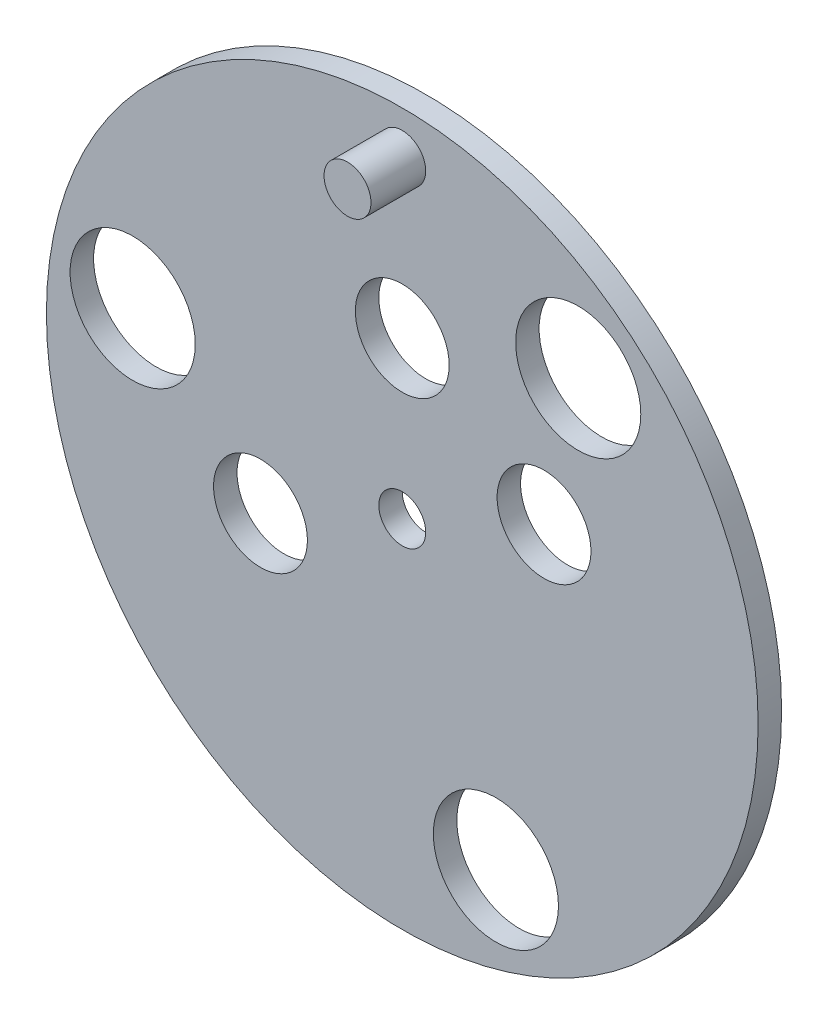
from build123d import *

# Parameters (mm, degrees)
SKETCH1_R           = 227.5
BOSS_EXTRUDE1_DEPTH = 7.5
BOSS_EXTRUDE2_START = 7.5
SKETCH1_3_R         = 15
BOSS_EXTRUDE2_DEPTH = 35
SKETCH2_R           = 40
SKETCH2_R_2         = 30
CUT_EXTRUDE1_DEPTH  = 16
CUT_EXTRUDE3_START  = 7.5
SKETCH3_R           = 15
CUT_EXTRUDE3_DEPTH  = 15


with BuildPart() as part:
    # Sketch1 → Boss-Extrude1 (new body, symmetric)
    with BuildSketch(Plane.XY):
        Circle(SKETCH1_R)
    extrude(amount=BOSS_EXTRUDE1_DEPTH, both=True)

    # Sketch1_3 → Boss-Extrude2 (add)
    with BuildSketch(Plane.XY.offset(BOSS_EXTRUDE2_START)):
        with Locations((0, 200)):
            Circle(SKETCH1_3_R)
    extrude(amount=BOSS_EXTRUDE2_DEPTH)

    # Sketch2 → Cut-Extrude1 (cut, through all)
    with BuildSketch(Plane.XY.offset(7.5)):
        with Locations((-172.341356777, 30.388431092)):
            Circle(SKETCH2_R)
        with Locations((0, 100)):
            Circle(SKETCH2_R_2)
        with Locations((90.630778704, 42.261826174)):
            Circle(SKETCH2_R_2)
        with Locations((-90.630778704, -42.261826174)):
            Circle(SKETCH2_R_2)
        with Locations((112.487831695, 134.057777546)):
            Circle(SKETCH2_R)
        with Locations((59.853525082, -164.446208638)):
            Circle(SKETCH2_R)
    extrude(amount=-CUT_EXTRUDE1_DEPTH, mode=Mode.SUBTRACT)

    # Sketch3 → Cut-Extrude3 (cut)
    with BuildSketch(Plane.XY.offset(CUT_EXTRUDE3_START)):
        Circle(SKETCH3_R)
    extrude(amount=-CUT_EXTRUDE3_DEPTH, mode=Mode.SUBTRACT)


solid = part.part
